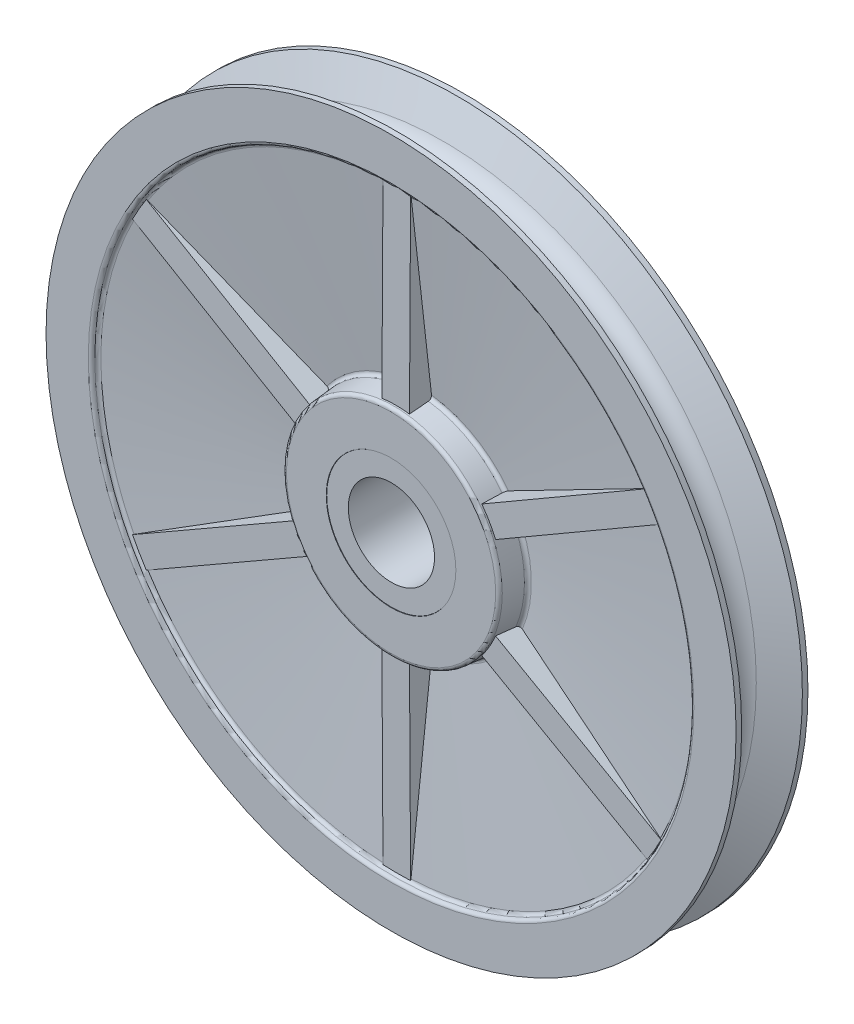
from build123d import *

# Parameters (mm, degrees)
SKETCH2_R                    = 14.3129
SKETCH2_R_2                  = 14.2875
CUT_EXTRUDE_THIN1_DEPTH      = 109.055004078
CUT_EXTRUDE_THIN1_DEPTH_BACK = 109.055004078
DRAFT1_ANGLE                 = 5
DRAFT2_ANGLE                 = 15
FILLET1_R                    = 0.762
FILLET2_R                    = 0.762
BOSS_EXTRUDE1_DEPTH          = 3.048
CIRPATTERN1_COUNT            = 6
CIRPATTERN1_COPY_1_DEPTH     = 3.048
CIRPATTERN1_COPY_2_DEPTH     = 3.048
CIRPATTERN1_COPY_3_DEPTH     = 3.048
CIRPATTERN1_COPY_4_DEPTH     = 3.048
CIRPATTERN1_COPY_5_DEPTH     = 3.048


with BuildPart() as part:
    # Sketch1 → Revolve1 (revolve)
    with BuildSketch(Plane(origin=(0, 0, 0), x_dir=(0, 0, -1), z_dir=(1, 0, 0)), mode=Mode.PRIVATE) as revolve1_sk:
        with BuildLine():
            Line((6.7056, 76.2), (7.9375, 76.2))
            Line((7.9375, 76.2), (7.9375, 66.167))
            Line((7.9375, 66.167), (6.6675, 66.167))
            Line((6.6675, 66.167), (1.905, 23.8125))
            Line((1.905, 23.8125), (7.9375, 23.8125))
            Line((7.9375, 23.8125), (7.9375, 14.2875))
            Line((7.9375, 14.2875), (7.8613, 14.2875))
            Line((7.8613, 14.2875), (7.8613, 9.525))
            Line((7.8613, 9.525), (-7.8613, 9.525))
            Line((-7.8613, 9.525), (-7.8613, 14.2875))
            Line((-7.8613, 14.2875), (-7.9375, 14.2875))
            Line((-7.9375, 14.2875), (-7.9375, 23.8125))
            Line((-7.9375, 23.8125), (-1.905, 23.8125))
            Line((-1.905, 23.8125), (-6.6675, 66.167))
            Line((-6.6675, 66.167), (-7.9375, 66.167))
            Line((-7.9375, 66.167), (-7.9375, 76.2))
            Line((-7.9375, 76.2), (-6.7056, 76.2))
            Line((-6.7056, 76.2), (-3.646654527, 69.077580365))
            ThreePointArc((-3.646654527, 69.077580365), (0, 66.675), (3.646654527, 69.077580365))
            Line((3.646654527, 69.077580365), (6.7056, 76.2))
        make_face()
    revolve(revolve1_sk.sketch.rotate(Axis((0, 0, 7.9375), (0, 0, -1)), 90), axis=Axis((0, 0, 7.9375), (0, 0, -1)))

    # Sketch2 → Cut-Extrude-Thin1 (cut, two sides)
    with BuildSketch(Plane.XY) as cut_extrude_thin1_sk:
        Circle(SKETCH2_R)
        Circle(SKETCH2_R_2, mode=Mode.SUBTRACT)
    extrude(amount=CUT_EXTRUDE_THIN1_DEPTH, mode=Mode.SUBTRACT)
    extrude(cut_extrude_thin1_sk.sketch, amount=-CUT_EXTRUDE_THIN1_DEPTH_BACK, mode=Mode.SUBTRACT)


with BuildPart() as cut_extrude_thin1_piece_1:
    # of the separate pieces the step leaves, piece 1, a body of its own (cut_extrude_thin1_pieces)
    add(part.part.solids().sort_by_distance((69.077580365, 0, -3.646654527))[0])

    # Draft1
    draft1_faces = [cut_extrude_thin1_piece_1.faces().sort_by_distance(p)[0] for p in [
        (-23.8125, 0, 4.92125),
        (-66.167, 0, 7.3025),
    ]]
    draft(draft1_faces, Plane(origin=(0, 66.167, 7.9375), x_dir=(1, 0, 0), z_dir=(0, 0, 1)), DRAFT1_ANGLE)

    # Draft2
    draft2_faces = [cut_extrude_thin1_piece_1.faces().sort_by_distance(p)[0] for p in [
        (-23.8125, 0, -4.92125),
        (-66.167, 0, -7.3025),
    ]]
    draft(draft2_faces, Plane(origin=(0, 76.2, -7.9375), x_dir=(-1, 0, 0), z_dir=(0, 0, -1)), DRAFT2_ANGLE)

    # Fillet1
    fillet1_edges = [cut_extrude_thin1_piece_1.edges().sort_by_distance(p)[0] for p in [
        (-66.167, 0, 7.9375),
        (-23.8125, 0, 7.9375),
        (-23.8125, 0, -7.9375),
        (-66.167, 0, -7.9375),
    ]]
    fillet(fillet1_edges, radius=FILLET1_R)

    # Fillet2
    fillet2_edges = [cut_extrude_thin1_piece_1.edges().sort_by_distance(p)[0] for p in [
        (-24.335133922, 0, 1.963766933),
        (-66.054785481, 0, 6.654882175),
    ]]
    fillet(fillet2_edges, radius=FILLET2_R)



with BuildPart() as cut_extrude_thin1_piece_2:
    # of the separate pieces the step leaves, piece 2, a body of its own (cut_extrude_thin1_pieces)
    add(part.part.solids().sort_by_distance((14.2875, 0, -7.8613))[0])


with BuildPart() as cut_extrude_thin1_piece_1_1:
    add(cut_extrude_thin1_piece_1.part)

    add(cut_extrude_thin1_piece_2.part)  # Boss-Extrude1 merges Cut-Extrude-Thin1 piece 2
    # Sketch5 → Boss-Extrude1 (add, symmetric)
    with BuildSketch(Plane(origin=(0, 0, 0), x_dir=(0, 0, -1), z_dir=(1, 0, 0))):
        Polygon((-6.9215, 22.5425), (-6.6675, 66.167), (0, 66.167), (0, 14.2875), (-6.9215, 14.2875), align=None)
    boss_extrude1 = extrude(amount=BOSS_EXTRUDE1_DEPTH, both=True)

    # Mirror1: Boss-Extrude1 across plane
    add(boss_extrude1.mirror(Plane.XY))

    # CirPattern1: Boss-Extrude1 ×6 about axis
    cirpattern1_axis = Axis((0, 0, 0), (0, 0, 1))
    for i in range(1, CIRPATTERN1_COUNT):
        add(boss_extrude1.rotate(cirpattern1_axis, i * 360 / CIRPATTERN1_COUNT))

    # CirPattern1 copy 1 sketch → CirPattern1 copy 1 (add, symmetric)
    with BuildSketch(Plane(origin=(0, 0, 0), x_dir=(0, 0, 1), z_dir=(0.5000000000000001, 0.8660254037844386, 0))):
        Polygon((-6.9215, -22.5425), (-6.6675, -66.167), (0, -66.167), (0, -14.2875), (-6.9215, -14.2875), align=None)
    extrude(amount=CIRPATTERN1_COPY_1_DEPTH, both=True)

    # CirPattern1 copy 2 sketch → CirPattern1 copy 2 (add, symmetric)
    with BuildSketch(Plane(origin=(0, 0, 0), x_dir=(0, 0, 1), z_dir=(-0.4999999999999998, 0.8660254037844387, 0))):
        Polygon((-6.9215, -22.5425), (-6.6675, -66.167), (0, -66.167), (0, -14.2875), (-6.9215, -14.2875), align=None)
    extrude(amount=CIRPATTERN1_COPY_2_DEPTH, both=True)

    # CirPattern1 copy 3 sketch → CirPattern1 copy 3 (add, symmetric)
    with BuildSketch(Plane.ZY):
        Polygon((-6.9215, -22.5425), (-6.6675, -66.167), (0, -66.167), (0, -14.2875), (-6.9215, -14.2875), align=None)
    extrude(amount=CIRPATTERN1_COPY_3_DEPTH, both=True)

    # CirPattern1 copy 4 sketch → CirPattern1 copy 4 (add, symmetric)
    with BuildSketch(Plane(origin=(0, 0, 0), x_dir=(0, 0, 1), z_dir=(-0.5000000000000004, -0.8660254037844384, 0))):
        Polygon((-6.9215, -22.5425), (-6.6675, -66.167), (0, -66.167), (0, -14.2875), (-6.9215, -14.2875), align=None)
    extrude(amount=CIRPATTERN1_COPY_4_DEPTH, both=True)

    # CirPattern1 copy 5 sketch → CirPattern1 copy 5 (add, symmetric)
    with BuildSketch(Plane(origin=(0, 0, 0), x_dir=(0, 0, 1), z_dir=(0.5000000000000001, -0.8660254037844386, 0))):
        Polygon((-6.9215, -22.5425), (-6.6675, -66.167), (0, -66.167), (0, -14.2875), (-6.9215, -14.2875), align=None)
    extrude(amount=CIRPATTERN1_COPY_5_DEPTH, both=True)


solid = cut_extrude_thin1_piece_1_1.part
